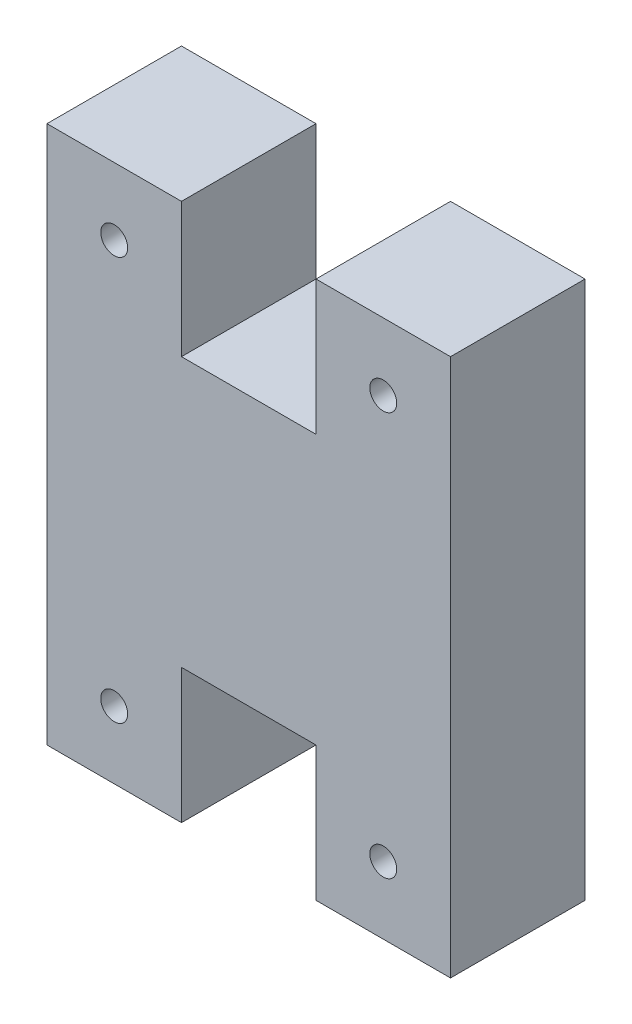
from build123d import *

# Parameters (mm, degrees)
SKETCH1_W           = 19.05
SKETCH1_H           = 25.4
BOSS_EXTRUDE1_DEPTH = 6.35
SKETCH2_W           = 6.35
SKETCH2_H           = 6.35
CUT_EXTRUDE1_DEPTH  = 7.35
SKETCH6_R           = 0.635
CUT_EXTRUDE2_DEPTH  = 7.35
SKETCH7_R           = 0.635
CUT_EXTRUDE3_DEPTH  = 7.35


with BuildPart() as part:
    # Sketch1 → Boss-Extrude1 (new body)
    with BuildSketch(Plane.XY):
        with Locations((9.525, 12.7)):
            Rectangle(SKETCH1_W, SKETCH1_H)
    extrude(amount=BOSS_EXTRUDE1_DEPTH)

    # Sketch2 → Cut-Extrude1 (cut, through all)
    with BuildSketch(Plane.XY.offset(6.35)):
        with Locations((9.525, 22.225)):
            Rectangle(SKETCH2_W, SKETCH2_H)
    cut_extrude1 = extrude(amount=-CUT_EXTRUDE1_DEPTH, mode=Mode.SUBTRACT)

    # Mirror1: Cut-Extrude1 across plane
    add(cut_extrude1.mirror(Plane.ZX.offset(12.7)), mode=Mode.SUBTRACT)

    # Sketch6 → Cut-Extrude2 (cut, through all)
    with BuildSketch(Plane.XY.offset(6.35)):
        with Locations((3.175, 22.225)):
            Circle(SKETCH6_R)
        with Locations((15.875, 22.225)):
            Circle(SKETCH6_R)
    extrude(amount=-CUT_EXTRUDE2_DEPTH, mode=Mode.SUBTRACT)

    # Sketch7 → Cut-Extrude3 (cut, through all)
    with BuildSketch(Plane(origin=(0, 0, 0), x_dir=(-1, 0, 0), z_dir=(0, 0, -1))):
        with Locations((-15.875, 3.175)):
            Circle(SKETCH7_R)
        with Locations((-3.175, 3.175)):
            Circle(SKETCH7_R)
    extrude(amount=-CUT_EXTRUDE3_DEPTH, mode=Mode.SUBTRACT)


solid = part.part
